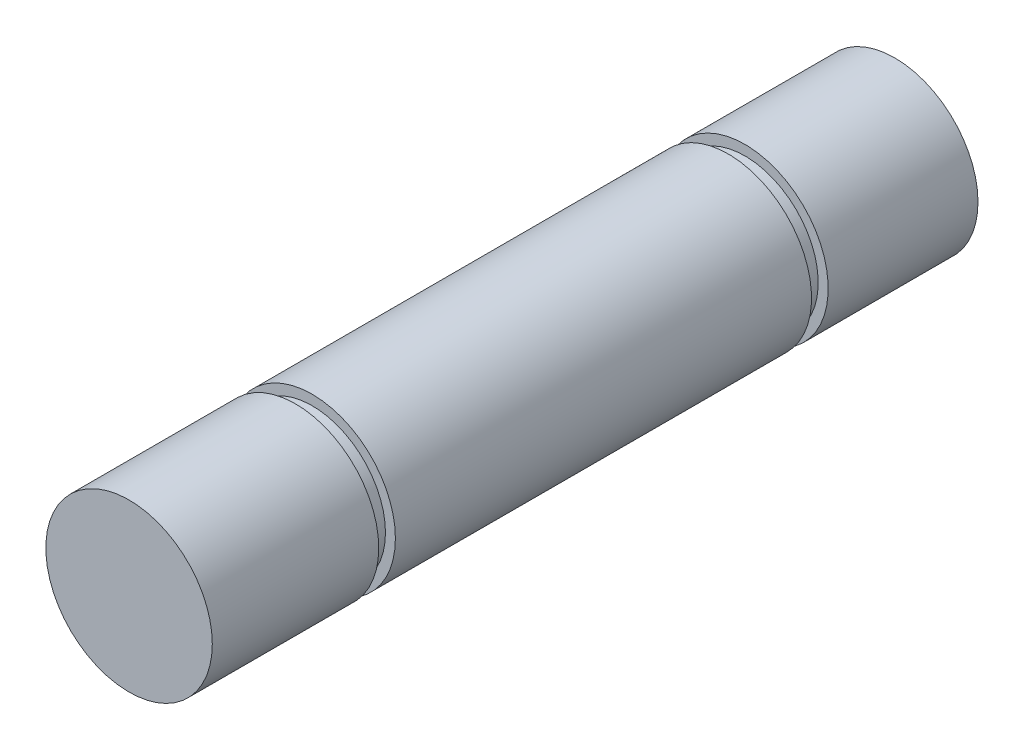
from build123d import *

# Parameters (mm, degrees)
SKETCH1_R                  = 2.5
BOSS_EXTRUDE1_DEPTH        = 23
WYTNIJ_WYCI_GNI_CIE1_START = -5
SZKIC1_R                   = 2.5
SZKIC1_R_2                 = 2.201367386
WYTNIJ_WYCI_GNI_CIE1_DEPTH = 0.5
WYTNIJ_WYCI_GNI_CIE2_START = -5
SZKIC2_R                   = 2.5
SZKIC2_R_2                 = 2.2
WYTNIJ_WYCI_GNI_CIE2_DEPTH = 0.5


with BuildPart() as part:
    # Sketch1 → Boss-Extrude1 (new body)
    with BuildSketch(Plane.XY):
        Circle(SKETCH1_R)
    extrude(amount=BOSS_EXTRUDE1_DEPTH)

    # Szkic1 → Wytnij-wyciągnięcie1 (cut)
    with BuildSketch(Plane.XY.offset(23).offset(WYTNIJ_WYCI_GNI_CIE1_START)):
        Circle(SZKIC1_R)
        Circle(SZKIC1_R_2, mode=Mode.SUBTRACT)
    extrude(amount=-WYTNIJ_WYCI_GNI_CIE1_DEPTH, mode=Mode.SUBTRACT)

    # Szkic2 → Wytnij-wyciągnięcie2 (cut)
    with BuildSketch(Plane(origin=(0, 0, 0), x_dir=(-1, 0, 0), z_dir=(0, 0, -1)).offset(WYTNIJ_WYCI_GNI_CIE2_START)):
        Circle(SZKIC2_R)
        Circle(SZKIC2_R_2, mode=Mode.SUBTRACT)
    extrude(amount=WYTNIJ_WYCI_GNI_CIE2_DEPTH, mode=Mode.SUBTRACT)


solid = part.part
